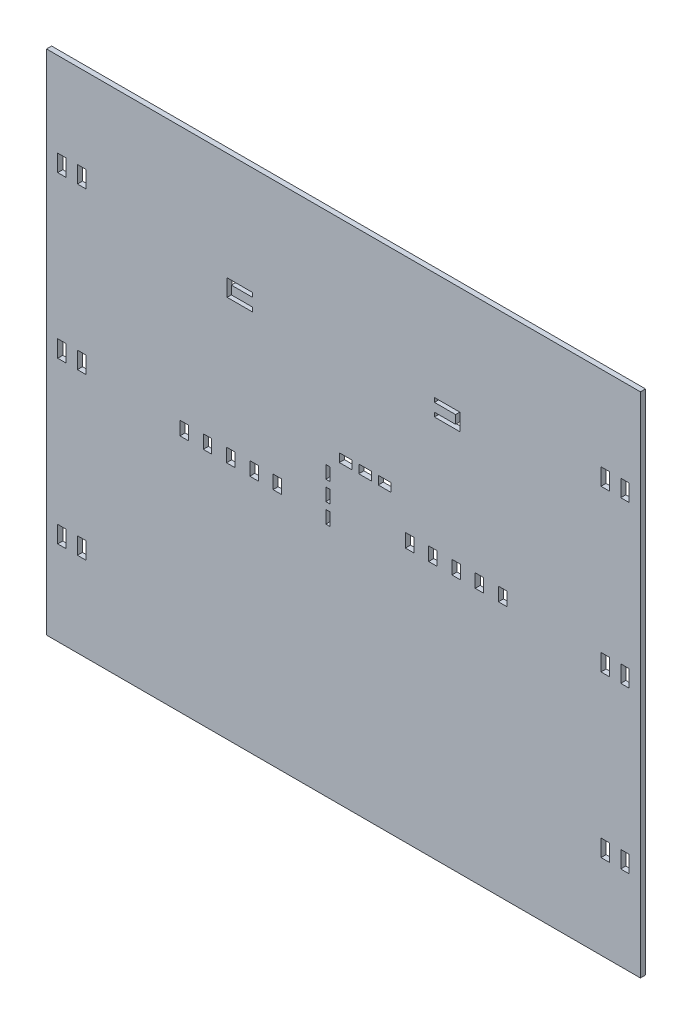
from build123d import *

# Parameters (mm, degrees)
SKETCH1_W           = 702.0123615
SKETCH1_H           = 600.05
SKETCH1_W_2         = 10
SKETCH1_H_2         = 20
SKETCH1_W_3         = 5
SKETCH1_H_3         = 15
SKETCH1_W_4         = 15
SKETCH1_H_4         = 10
BOSS_EXTRUDE2_DEPTH = 6


with BuildPart() as part:
    # Sketch1 → Boss-Extrude2 (new body)
    with BuildSketch(Plane.XY):
        Rectangle(SKETCH1_W, SKETCH1_H)
        with Locations((-332.772847417, -190.025)):
            Rectangle(SKETCH1_W_2, SKETCH1_H_2, mode=Mode.SUBTRACT)
        with Locations((-309.439514083, -190.025)):
            Rectangle(SKETCH1_W_2, SKETCH1_H_2, mode=Mode.SUBTRACT)
        Polygon((-193.20062859, -9.2), (-193.20062859, -1.2), (-183.20062859, -1.2), (-183.20062859, -9.2), (-183.20062859, -17.2), (-193.20062859, -17.2), align=None, mode=Mode.SUBTRACT)
        Polygon((-155.70062859, -1.2), (-155.70062859, -9.2), (-155.70062859, -17.2), (-165.70062859, -17.2), (-165.70062859, -9.2), (-165.70062859, -1.2), align=None, mode=Mode.SUBTRACT)
        Polygon((-128.20062859, -1.2), (-128.20062859, -9.2), (-128.20062859, -17.2), (-138.20062859, -17.2), (-138.20062859, -9.2), (-138.20062859, -1.2), align=None, mode=Mode.SUBTRACT)
        Polygon((-100.70062859, -1.2), (-100.70062859, -9.2), (-100.70062859, -17.2), (-110.70062859, -17.2), (-110.70062859, -9.2), (-110.70062859, -1.2), align=None, mode=Mode.SUBTRACT)
        Polygon((-73.20062859, -1.2), (-73.20062859, -9.2), (-73.20062859, -17.2), (-83.20062859, -17.2), (-83.20062859, -9.2), (-83.20062859, -1.2), align=None, mode=Mode.SUBTRACT)
        with Locations((-18.35, -13.8)):
            Rectangle(SKETCH1_W_3, SKETCH1_H_3, mode=Mode.SUBTRACT)
        with Locations((309.439514083, -190.025)):
            Rectangle(SKETCH1_W_2, SKETCH1_H_2, mode=Mode.SUBTRACT)
        with Locations((332.772847417, -190.025)):
            Rectangle(SKETCH1_W_2, SKETCH1_H_2, mode=Mode.SUBTRACT)
        with Locations((-332.772847417, 0)):
            Rectangle(SKETCH1_W_2, SKETCH1_H_2, mode=Mode.SUBTRACT)
        with Locations((-309.439514083, 0)):
            Rectangle(SKETCH1_W_2, SKETCH1_H_2, mode=Mode.SUBTRACT)
        with Locations((-18.35, 9.2)):
            Rectangle(SKETCH1_W_3, SKETCH1_H_3, mode=Mode.SUBTRACT)
        with Locations((-18.35, 32.2)):
            Rectangle(SKETCH1_W_3, SKETCH1_H_3, mode=Mode.SUBTRACT)
        with Locations((-332.772847417, 190.025)):
            Rectangle(SKETCH1_W_2, SKETCH1_H_2, mode=Mode.SUBTRACT)
        with Locations((-309.439514083, 190.025)):
            Rectangle(SKETCH1_W_2, SKETCH1_H_2, mode=Mode.SUBTRACT)
        Polygon((-132.5, 167.5), (-132.5, 157.5), (-107.5, 157.5), (-107.5, 152.5), (-132.5, 152.5), (-137.5, 152.5), (-137.5, 172.5), (-132.5, 172.5), (-107.5, 172.5), (-107.5, 167.5), align=None, mode=Mode.SUBTRACT)
        Polygon((83.20052308, 17.2), (83.20052308, 9.2), (83.20052308, 1.2), (73.20052308, 1.2), (73.20052308, 9.2), (73.20052308, 17.2), align=None, mode=Mode.SUBTRACT)
        with Locations((2.65, 54.7)):
            Rectangle(SKETCH1_W_4, SKETCH1_H_4, mode=Mode.SUBTRACT)
        with Locations((25.65, 54.7)):
            Rectangle(SKETCH1_W_4, SKETCH1_H_4, mode=Mode.SUBTRACT)
        with Locations((48.65, 54.7)):
            Rectangle(SKETCH1_W_4, SKETCH1_H_4, mode=Mode.SUBTRACT)
        Polygon((110.70052308, 17.2), (110.70052308, 9.2), (110.70052308, 1.2), (100.70052308, 1.2), (100.70052308, 9.2), (100.70052308, 17.2), align=None, mode=Mode.SUBTRACT)
        Polygon((138.20052308, 17.2), (138.20052308, 9.2), (138.20052308, 1.2), (128.20052308, 1.2), (128.20052308, 9.2), (128.20052308, 17.2), align=None, mode=Mode.SUBTRACT)
        Polygon((165.70052308, 17.2), (165.70052308, 9.2), (165.70052308, 1.2), (155.70052308, 1.2), (155.70052308, 9.2), (155.70052308, 17.2), align=None, mode=Mode.SUBTRACT)
        Polygon((193.20052308, 17.2), (193.20052308, 9.2), (193.20052308, 1.2), (183.20052308, 1.2), (183.20052308, 9.2), (183.20052308, 17.2), align=None, mode=Mode.SUBTRACT)
        with Locations((309.439514083, 0)):
            Rectangle(SKETCH1_W_2, SKETCH1_H_2, mode=Mode.SUBTRACT)
        with Locations((332.772847417, 0)):
            Rectangle(SKETCH1_W_2, SKETCH1_H_2, mode=Mode.SUBTRACT)
        Polygon((107.5, 167.5), (107.5, 172.5), (132.5, 172.5), (137.5, 172.5), (137.5, 152.5), (132.5, 152.5), (107.5, 152.5), (107.5, 157.5), (132.5, 157.5), (132.5, 167.5), align=None, mode=Mode.SUBTRACT)
        with Locations((309.439514083, 190.025)):
            Rectangle(SKETCH1_W_2, SKETCH1_H_2, mode=Mode.SUBTRACT)
        with Locations((332.772847417, 190.025)):
            Rectangle(SKETCH1_W_2, SKETCH1_H_2, mode=Mode.SUBTRACT)
    extrude(amount=BOSS_EXTRUDE2_DEPTH)


solid = part.part
